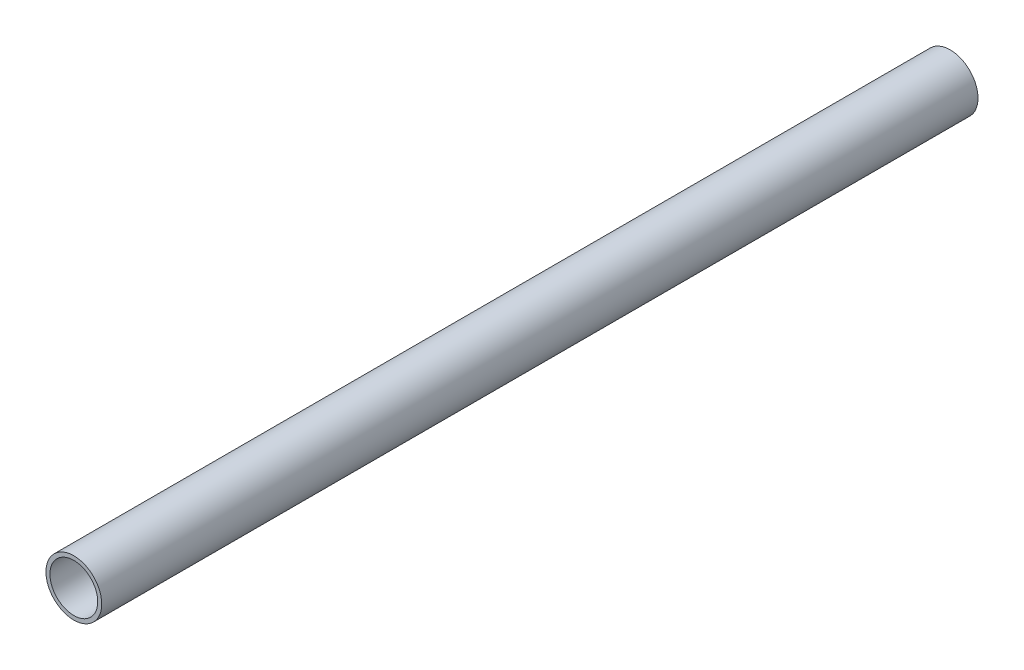
from build123d import *

# Parameters (mm, degrees)
ESBO_O1_R                = 7
ESBO_O1_R_2              = 6
RESSALTO_EXTRUS_O1_DEPTH = 220


with BuildPart() as part:
    # Esboço1 → Ressalto-extrusão1 (new body)
    with BuildSketch(Plane.XY):
        Circle(ESBO_O1_R)
        Circle(ESBO_O1_R_2, mode=Mode.SUBTRACT)
    extrude(amount=RESSALTO_EXTRUS_O1_DEPTH)


solid = part.part
